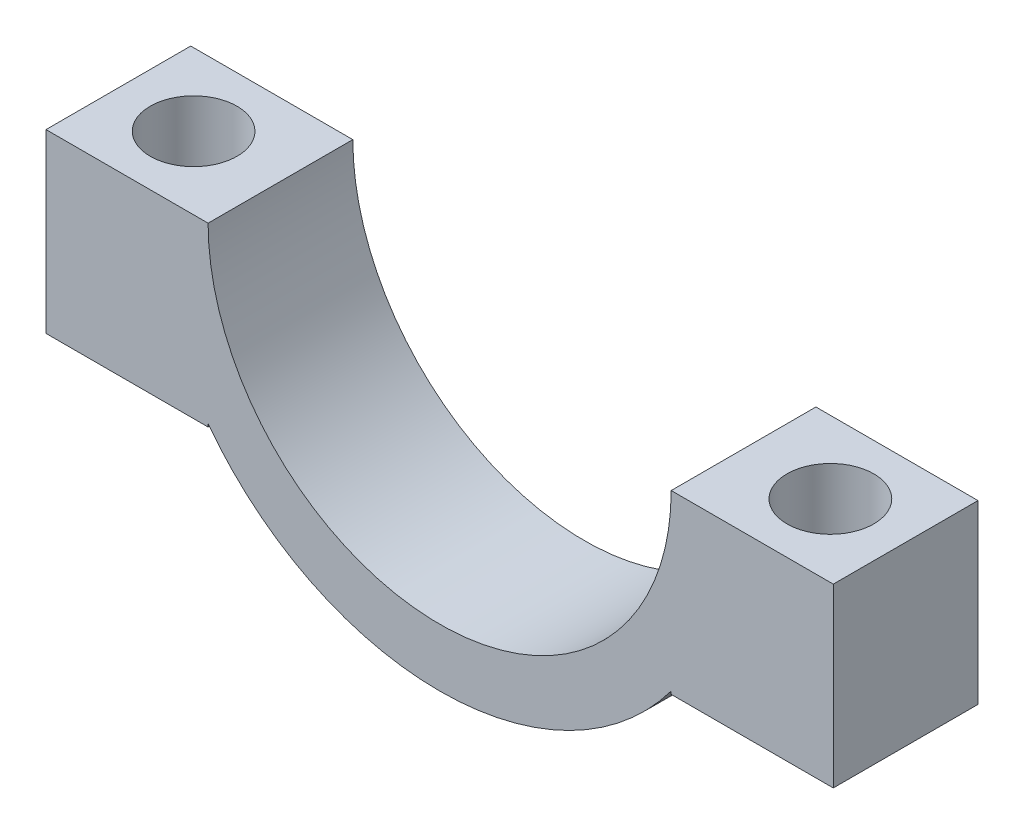
from build123d import *

# Parameters (mm, degrees)
BOSS_EXTRUDE1_DEPTH = 5
SKETCH3_R           = 1.5
CUT_EXTRUDE1_DEPTH  = 10


with BuildPart() as part:
    # Sketch2 → Boss-Extrude1 (new body)
    with BuildSketch(Plane.XY):
        with BuildLine():
            ThreePointArc((-8, -6), (0, -10), (8, -6))
            Line((8, -6), (8, -6.1))
            Line((8, -6.1), (13.6, -6.1))
            Line((13.6, -6.1), (13.6, 0))
            Line((13.6, 0), (8, 0))
            ThreePointArc((8, 0), (0, -8), (-8, 0))
            Line((-8, 0), (-13.6, 0))
            Line((-13.6, 0), (-13.6, -6.1))
            Line((-13.6, -6.1), (-8, -6.1))
            Line((-8, -6.1), (-8, -6))
        make_face()
    extrude(amount=BOSS_EXTRUDE1_DEPTH)

    # Sketch3 → Cut-Extrude1 (cut)
    with BuildSketch(Plane(origin=(0, 0, 0), x_dir=(1, 0, 0), z_dir=(0, 1, 0))):
        with Locations((-11, -2.5)):
            Circle(SKETCH3_R)
        with Locations((11, -2.5)):
            Circle(SKETCH3_R)
    extrude(amount=-CUT_EXTRUDE1_DEPTH, mode=Mode.SUBTRACT)


solid = part.part
